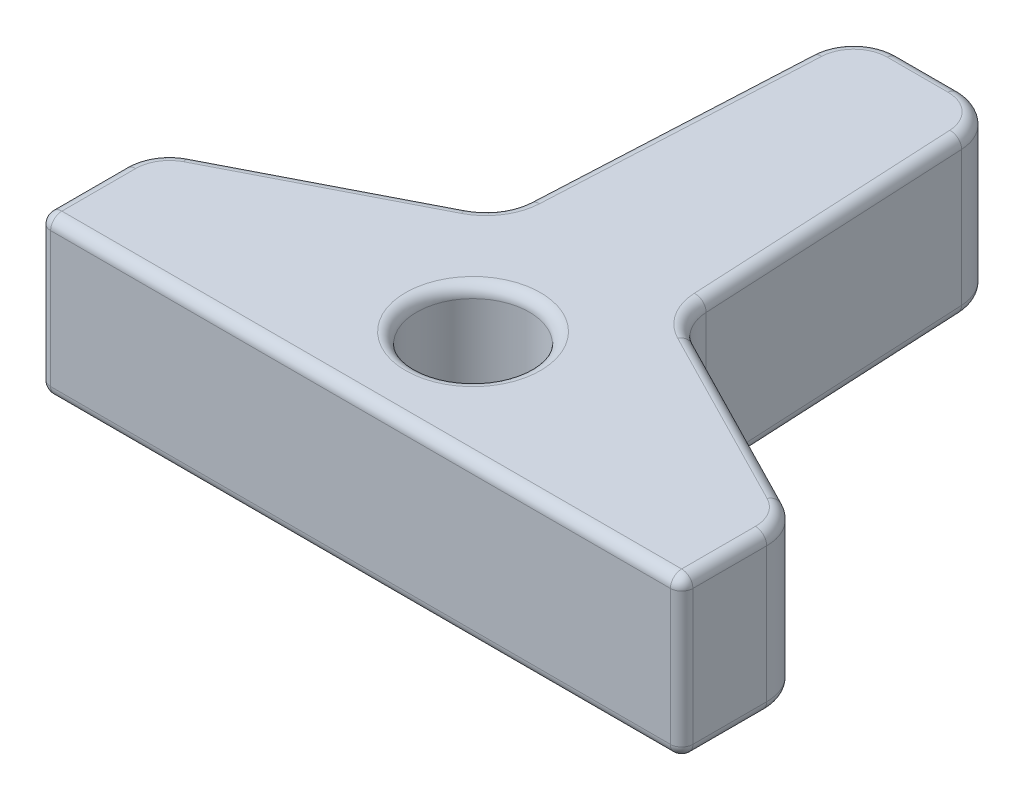
from build123d import *

# Parameters (mm, degrees)
SKETCH1_R           = 2.5
BOSS_EXTRUDE1_DEPTH = 7
FILLET1_R           = 2
FILLET2_R           = 0.5


with BuildPart() as part:
    # Sketch1 → Boss-Extrude1 (new body)
    with BuildSketch(Plane(origin=(0, 0, 0), x_dir=(1, 0, 0), z_dir=(0, 1, 0))):
        Polygon((-23.791870344, 12.96668262), (-17.291870344, 12.96668262), (-16.541870344, -2.03331738), (-6.271908742, -7.297228373), (-6.271908742, -12.297228373), (-34.811831945, -12.297228373), (-34.811831945, -7.297228373), (-24.541870344, -2.03331738), align=None)
        with Locations((-20.541870344, -7.297228373)):
            Circle(SKETCH1_R, mode=Mode.SUBTRACT)
    extrude(amount=BOSS_EXTRUDE1_DEPTH)

    # Fillet1
    fillet1_edges = [part.edges().sort_by_distance(p)[0] for p in [
        (-23.791870344, 3.5, -12.96668262),
        (-17.291870344, 3.5, -12.96668262),
        (-16.541870344, 3.5, 2.03331738),
        (-6.271908742, 3.5, 7.297228373),
        (-34.811831945, 3.5, 7.297228373),
        (-24.541870344, 3.5, 2.03331738),
    ]]
    fillet(fillet1_edges, radius=FILLET1_R)

    # Fillet2
    fillet2_edges = [part.edges().sort_by_distance(p)[0] for p in [
        (-20.541870344, 0, 12.297228373),
        (-34.811831945, 7, 10.408378726),
        (-34.811831945, 0, 10.408378726),
        (-20.541870344, 7, 12.297228373),
        (-6.271908742, 3.5, 12.297228373),
        (-34.811831945, 3.5, 12.297228373),
        (-11.436968701, 0, 4.649855681),
        (-11.436968701, 7, 4.649855681),
        (-24.185541966, 0, -5.093250169),
        (-20.541870344, 0, -12.96668262),
        (-16.898198721, 0, -5.093250169),
        (-6.271908742, 0, 10.408378726),
        (-29.646771987, 0, 4.649855681),
        (-17.815918651, 0, -12.415777246),
        (-23.267822036, 0, -12.415777246),
        (-34.518365815, 0, 7.476580302),
        (-6.565374872, 0, 7.476580302),
        (-6.271908742, 7, 10.408378726),
        (-23.041870344, 7, 7.297228373),
        (-24.185541966, 7, -5.093250169),
        (-29.646771987, 7, 4.649855681),
        (-16.898198721, 7, -5.093250169),
        (-20.541870344, 7, -12.96668262),
        (-17.815918651, 7, -12.415777246),
        (-23.267822036, 7, -12.415777246),
        (-34.518365815, 7, 7.476580302),
        (-6.565374872, 7, 7.476580302),
        (-16.281980837, 0, 1.865429111),
        (-16.281980837, 7, 1.865429111),
        (-24.80175985, 0, 1.865429111),
        (-24.80175985, 7, 1.865429111),
        (-23.041870344, 0, 7.297228373),
    ]]
    fillet(fillet2_edges, radius=FILLET2_R)


solid = part.part
